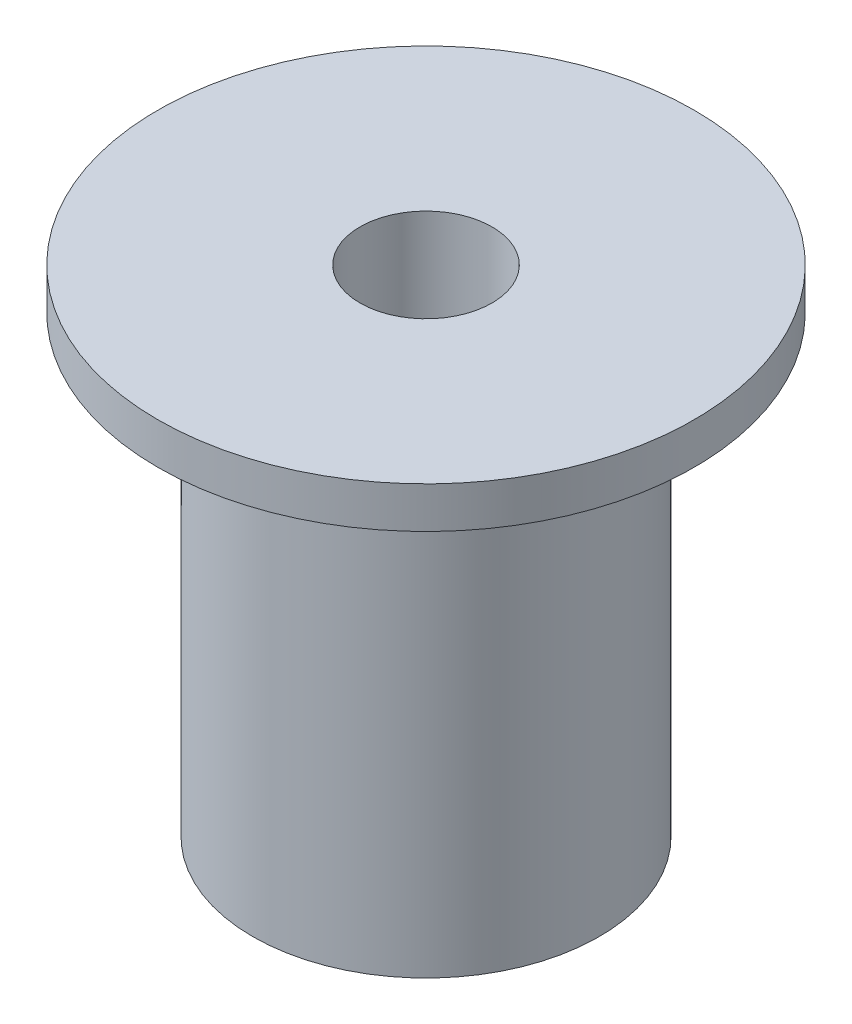
from build123d import *

# Parameters (mm, degrees)
SKETCH1_R           = 4.2
SKETCH1_R_2         = 1.6
BOSS_EXTRUDE1_DEPTH = 11
SKETCH2_R           = 6.5
SKETCH2_R_2         = 1.6
BOSS_EXTRUDE2_DEPTH = 1


with BuildPart() as part:
    # Sketch1 → Boss-Extrude1 (new body)
    with BuildSketch(Plane(origin=(0, 0, 0), x_dir=(1, 0, 0), z_dir=(0, 1, 0))):
        Circle(SKETCH1_R)
        Circle(SKETCH1_R_2, mode=Mode.SUBTRACT)
    extrude(amount=BOSS_EXTRUDE1_DEPTH)

    # Sketch2 → Boss-Extrude2 (add)
    with BuildSketch(Plane(origin=(0, 11, 0), x_dir=(1, 0, 0), z_dir=(0, 1, 0))):
        Circle(SKETCH2_R)
        Circle(SKETCH2_R_2, mode=Mode.SUBTRACT)
    extrude(amount=BOSS_EXTRUDE2_DEPTH)


solid = part.part
